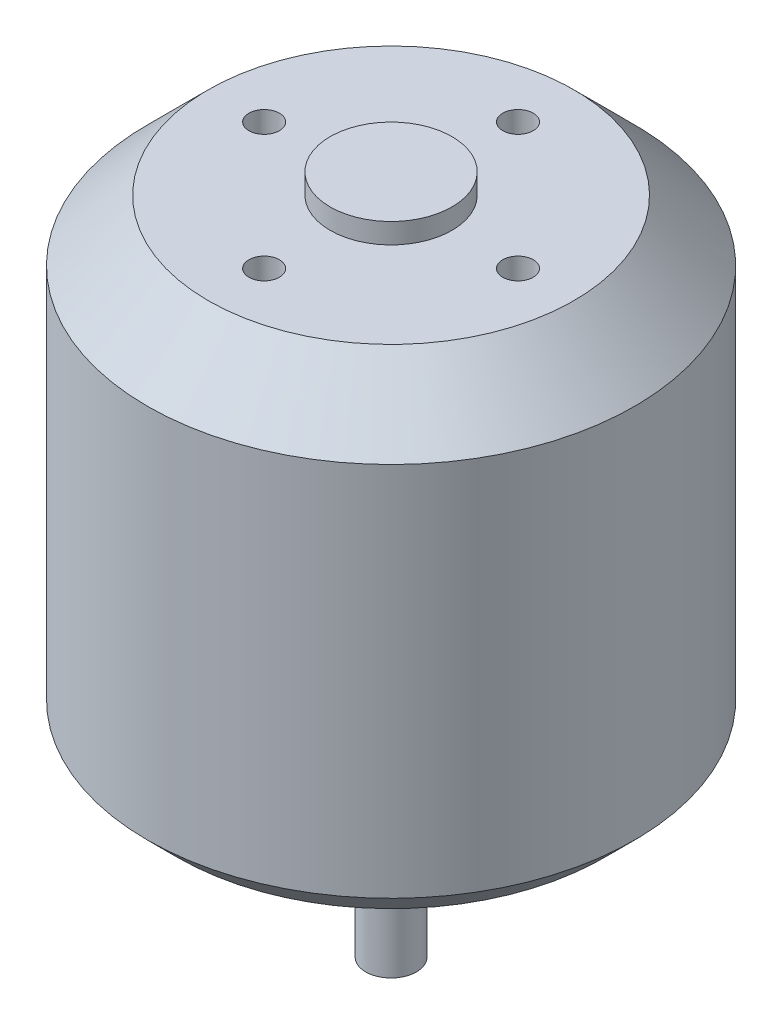
from build123d import *

# Parameters (mm, degrees)
SKETCH_1_R          = 24
EXTRUDE_1_DEPTH     = 46
SKETCH_3_R          = 6
EXTRUDE_2_DEPTH     = 2
CHAMFER_1_SIZE      = 6
CHAMFER_2_SIZE      = 3
SKETCH_4_R          = 1.5
CUT_EXTRUDE_1_DEPTH = 8
SKETCH_5_R          = 1.5
CUT_EXTRUDE_2_DEPTH = 8
SKETCH_6_R          = 2.5
EXTRUDE_3_DEPTH     = 19


with BuildPart() as part:
    # 草图1 → 凸台-拉伸1 (new body)
    with BuildSketch(Plane(origin=(0, 0, 0), x_dir=(1, 0, 0), z_dir=(0, 1, 0))):
        Circle(SKETCH_1_R)
    extrude(amount=EXTRUDE_1_DEPTH)

    # 草图3 → 凸台-拉伸2 (add)
    with BuildSketch(Plane(origin=(0, 46, 0), x_dir=(1, 0, 0), z_dir=(0, 1, 0))):
        Circle(SKETCH_3_R)
    extrude(amount=EXTRUDE_2_DEPTH)

    # 倒角1
    chamfer_1_edges = [part.edges().sort_by_distance(p)[0] for p in [
        (-24, 46, 0),
    ]]
    chamfer(chamfer_1_edges, length=CHAMFER_1_SIZE)

    # 倒角2
    chamfer_2_edges = [part.edges().sort_by_distance(p)[0] for p in [
        (-24, 0, 0),
    ]]
    chamfer(chamfer_2_edges, length=CHAMFER_2_SIZE)

    # 草图4 → 切除-拉伸1 (cut)
    with BuildSketch(Plane.XZ.offset(-46)):
        with Locations((0, 12.5)):
            Circle(SKETCH_4_R)
        with Locations((-12.5, 0)):
            Circle(SKETCH_4_R)
        with Locations((12.5, 0)):
            Circle(SKETCH_4_R)
        with Locations((0, -12.5)):
            Circle(SKETCH_4_R)
    extrude(amount=CUT_EXTRUDE_1_DEPTH, mode=Mode.SUBTRACT)

    # 草图5 → 切除-拉伸2 (cut)
    with BuildSketch(Plane.XZ):
        with Locations((0, 8.5)):
            Circle(SKETCH_5_R)
        with Locations((8.5, 0)):
            Circle(SKETCH_5_R)
        with Locations((0, -8.5)):
            Circle(SKETCH_5_R)
        with Locations((-8.5, 0)):
            Circle(SKETCH_5_R)
    extrude(amount=-CUT_EXTRUDE_2_DEPTH, mode=Mode.SUBTRACT)

    # 草图6 → 凸台-拉伸3 (add)
    with BuildSketch(Plane.XZ):
        Circle(SKETCH_6_R)
    extrude(amount=EXTRUDE_3_DEPTH)


solid = part.part
